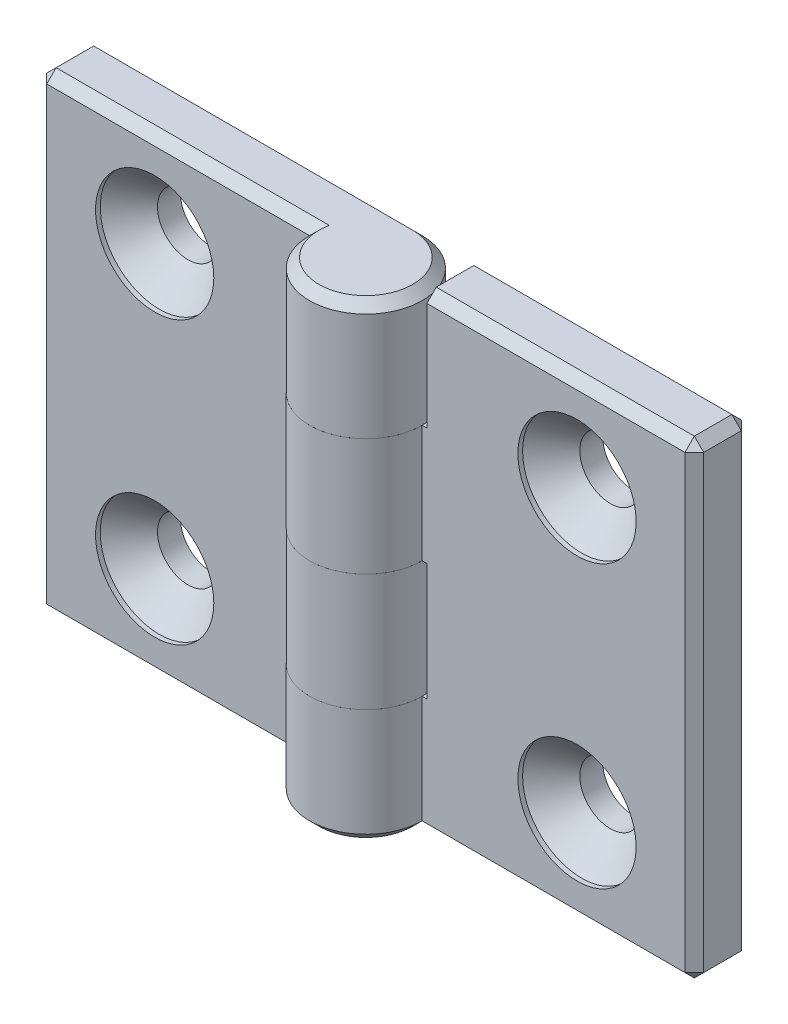
from build123d import *

# Parameters (mm, degrees)
EXTRUDE_1_DEPTH            = 25
SKETCH_3_W                 = 12.5
SKETCH_3_H                 = 12.5
CUT_EXTRUDE_1_DEPTH        = 7
CUT_EXTRUDE_1_DEPTH_BACK   = 7
HOLE_WIZARD_M61_AT_2_COUNT = 2
HOLE_WIZARD_M61_AT_2_PITCH = 30
CHAMFER_1_SIZE             = 1
PATTERN_CIRCULAR_1_COUNT   = 2


with BuildPart() as part:
    # Эскиз1 → Бобышка-Вытянуть1 (new body, symmetric)
    with BuildSketch(Plane(origin=(0, 0, 0), x_dir=(1, 0, 0), z_dir=(0, 1, 0))):
        with BuildLine():
            Line((0, 6), (-35, 6))
            Line((-35, 6), (-35, 0))
            Line((-35, 0), (-6, 0))
            ThreePointArc((-6, 0), (4.242640687, -4.242640687), (0, 6))
        make_face()
    extrude(amount=EXTRUDE_1_DEPTH, both=True)

    # Эскиз3 → Вырез-Вытянуть1 (cut, two sides)
    with BuildSketch(Plane.XY) as cut_extrude_1_sk:
        with Locations((-0.25, 6.25)):
            Rectangle(SKETCH_3_W, SKETCH_3_H)
        with Locations((-0.25, -18.75)):
            Rectangle(SKETCH_3_W, SKETCH_3_H)
    extrude(amount=CUT_EXTRUDE_1_DEPTH, mode=Mode.SUBTRACT)
    extrude(cut_extrude_1_sk.sketch, amount=-CUT_EXTRUDE_1_DEPTH_BACK, mode=Mode.SUBTRACT)

    # Эскиз6 → Зенковка для винта с полупотайной головкой M61 (revolve, cut)
    with BuildSketch(Plane(origin=(-22.5, 15, 0), x_dir=(0, -1, 0), z_dir=(1, 0, 0))):
        Polygon((0, 0), (0, 6), (3.25, 6), (3.25, 3.55), (6.3, 0.5), (6.3, 0), align=None)
    hole_wizard_m61 = revolve(axis=Axis((-22.5, 15, 6.35), (0, 0, -1)), mode=Mode.SUBTRACT)

    # Зенковка для винта с полупотайной головкой M61 at 2: Зенковка для винта с полупотайной головкой M61 ×2
    with Locations(*[(0, -i * HOLE_WIZARD_M61_AT_2_PITCH, 0) for i in range(1, HOLE_WIZARD_M61_AT_2_COUNT)]):
        add(hole_wizard_m61, mode=Mode.SUBTRACT)

    # Фаска1
    chamfer_1_edges = [part.edges().sort_by_distance(p)[0] for p in [
        (-35, 25, -3),
        (-20.75, -25, -6),
        (-20.5, 25, 0),
        (4.242640687, 25, 4.242640687),
        (-20.75, -25, 0),
        (-35, -25, -3),
        (-35, 0, 0),
        (-35, 0, -6),
        (-17.5, 25, -6),
    ]]
    chamfer(chamfer_1_edges, length=CHAMFER_1_SIZE)


with BuildPart() as pattern_circular_1_1:
    # Круговой массив1: pattern copy
    add(part.part.rotate(Axis((0, 0, 0), (0, 0, 1)), 1 * 360 / PATTERN_CIRCULAR_1_COUNT))


solid = Compound([part.part, pattern_circular_1_1.part])
